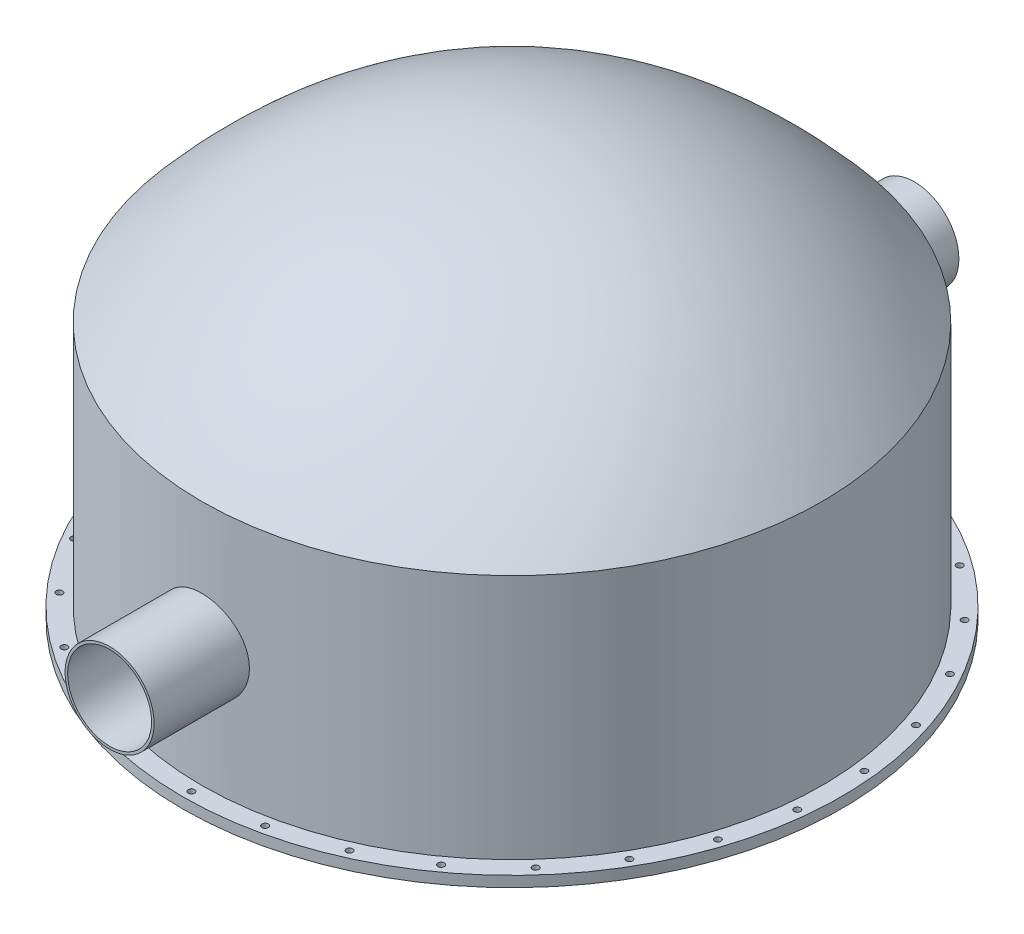
from build123d import *

# Parameters (mm, degrees)
BOSS_EXTRUDE1_START = -652.942491
SKETCH3_R           = 304.8
BOSS_EXTRUDE1_DEPTH = 652.942491
SKETCH4_R           = 287.4
CUT_EXTRUDE1_DEPTH  = 5515.0000001
SKETCH5_R           = 22
CUT_EXTRUDE2_DEPTH  = 73


with BuildPart() as part:
    # Sketch1 → Revolve1 (revolve)
    with BuildSketch(Plane(origin=(0, 0, 0), x_dir=(0, 0, -1), z_dir=(1, 0, 0))):
        with BuildLine():
            Line((-2081.13, 0), (-2081.13, -1741.115))
            Line((-2081.13, -1741.115), (-2258.02, -1741.115))
            Line((-2258.02, -1741.115), (-2258.02, -1668.115))
            Line((-2258.02, -1668.115), (-2126.02, -1668.115))
            Line((-2126.02, -1668.115), (-2126.02, 16.908694058))
            add(Edge.make_bspline(
                [(0, 1089.3), (-223.462111711, 1089.311057215), (-581.422471541, 1026.211890554), (-859.810917531, 942.072223216), (-1130.019387147, 824.365036373), (-1391.8991989, 673.235294536), (-1613.69332384, 511.89661327), (-1768.176969901, 381.130401339), (-1874.480833736, 282.364998713), (-1949.431957446, 207.95119084), (-2001.441268917, 154.058336721), (-2038.346667779, 114.5979888), (-2064.066656222, 86.525362358), (-2082.377199325, 66.232230793), (-2095.16609191, 51.91461534), (-2104.286077598, 41.627045393), (-2110.661880175, 34.399277298), (-2115.215669271, 29.216268924), (-2121.510582718, 22.044882998), (-2126.02, 16.908694058)],
                knots=[0, 0, 0, 0.188640612, 0.31440102, 0.440161428, 0.565921836, 0.691682244, 0.78600255, 0.848882754, 0.896042907, 0.927483009, 0.951063086, 0.966783137, 0.978573175, 0.9864332, 0.99232822, 0.996258232, 0.999205742, 1.001170748, 1.006083264, 1.006083264, 1.006083264], degree=2))
            Line((0, 1089.3), (0, 1044.41))
            add(Edge.make_bspline(
                [(0, 1044.41), (-1164.248075476, 1044.41), (-2081.13, 0)],
                knots=[0, 0, 0, 1, 1, 1], degree=2))
        make_face()
    revolve(axis=Axis((0, 1298.817564103, 0), (0, -1, 0)))

    # Sketch3 → Boss-Extrude1 (add)
    with BuildSketch(Plane.XY.offset(2757).offset(BOSS_EXTRUDE1_START)):
        with Locations((0, -832.615)):
            Circle(SKETCH3_R)
    boss_extrude1 = extrude(amount=BOSS_EXTRUDE1_DEPTH)

    # Mirror1: Boss-Extrude1 across plane
    add(boss_extrude1.mirror(Plane.XY))

    # Sketch4 → Cut-Extrude1 (cut, through all)
    with BuildSketch(Plane.XY.offset(2757)):
        with Locations((0, -832.615)):
            Circle(SKETCH4_R)
    extrude(amount=-CUT_EXTRUDE1_DEPTH, mode=Mode.SUBTRACT)

    # Sketch5 → Cut-Extrude2 (cut)
    with BuildSketch(Plane.XZ.offset(1741.115)):
        with Locations((0, 2196.0235)):
            Circle(SKETCH5_R)
        with Locations((456.578958961, 2148.03511768)):
            Circle(SKETCH5_R)
        with Locations((893.203226506, 2006.167293301)):
            Circle(SKETCH5_R)
        with Locations((1290.790226988, 1776.620331547)):
            Circle(SKETCH5_R)
        with Locations((1631.963500652, 1469.426536133)):
            Circle(SKETCH5_R)
        with Locations((1901.812138308, 1098.01175)):
            Circle(SKETCH5_R)
        with Locations((2088.542459612, 678.608581547)):
            Circle(SKETCH5_R)
        with Locations((2183.993453493, 229.546961755)):
            Circle(SKETCH5_R)
        with Locations((2183.993453493, -229.546961755)):
            Circle(SKETCH5_R)
        with Locations((2088.542459612, -678.608581547)):
            Circle(SKETCH5_R)
        with Locations((1901.812138308, -1098.01175)):
            Circle(SKETCH5_R)
        with Locations((1631.963500652, -1469.426536133)):
            Circle(SKETCH5_R)
        with Locations((1290.790226988, -1776.620331547)):
            Circle(SKETCH5_R)
        with Locations((893.203226506, -2006.167293301)):
            Circle(SKETCH5_R)
        with Locations((456.578958961, -2148.03511768)):
            Circle(SKETCH5_R)
        with Locations((0, -2196.0235)):
            Circle(SKETCH5_R)
        with Locations((-456.57895896, -2148.03511768)):
            Circle(SKETCH5_R)
        with Locations((-893.203226505, -2006.167293301)):
            Circle(SKETCH5_R)
        with Locations((-1290.790226988, -1776.620331547)):
            Circle(SKETCH5_R)
        with Locations((-1631.963500652, -1469.426536133)):
            Circle(SKETCH5_R)
        with Locations((-1901.812138307, -1098.01175)):
            Circle(SKETCH5_R)
        with Locations((-2088.542459612, -678.608581547)):
            Circle(SKETCH5_R)
        with Locations((-2183.993453493, -229.546961755)):
            Circle(SKETCH5_R)
        with Locations((-2183.993453493, 229.546961755)):
            Circle(SKETCH5_R)
        with Locations((-2088.542459612, 678.608581547)):
            Circle(SKETCH5_R)
        with Locations((-1901.812138308, 1098.01175)):
            Circle(SKETCH5_R)
        with Locations((-1631.963500652, 1469.426536133)):
            Circle(SKETCH5_R)
        with Locations((-1290.790226988, 1776.620331547)):
            Circle(SKETCH5_R)
        with Locations((-893.203226506, 2006.167293301)):
            Circle(SKETCH5_R)
        with Locations((-456.578958961, 2148.03511768)):
            Circle(SKETCH5_R)
    extrude(amount=-CUT_EXTRUDE2_DEPTH, mode=Mode.SUBTRACT)


solid = part.part
